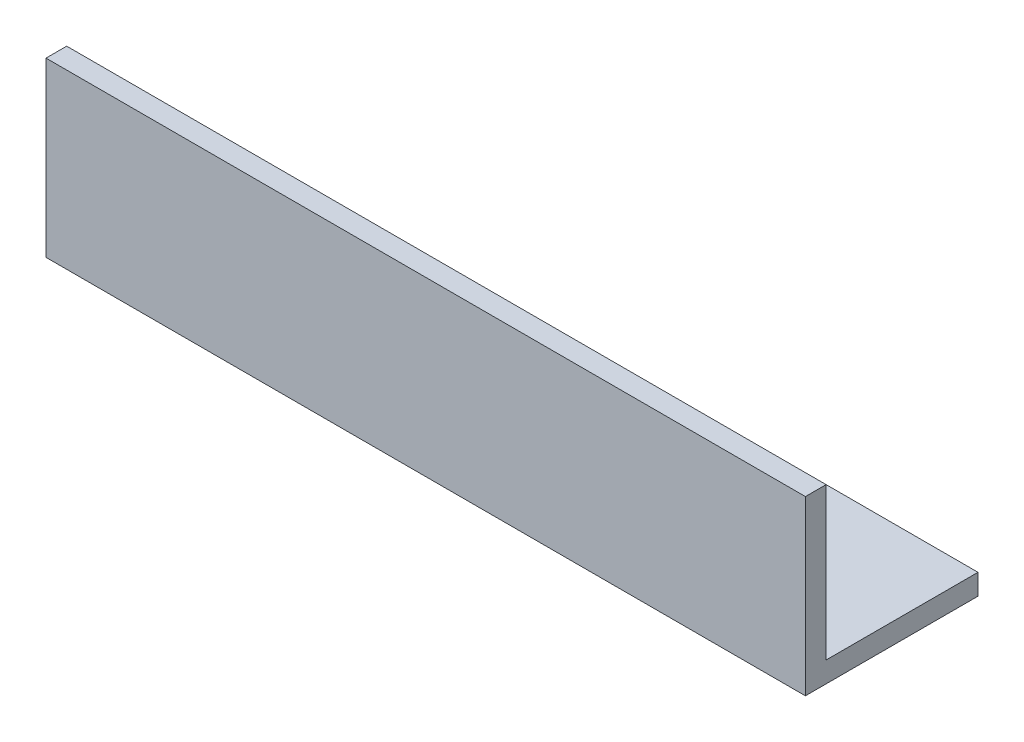
from build123d import *

# Parameters (mm, degrees)
EXTRUDE_1_DEPTH = 110


with BuildPart() as part:
    # Эскиз1 → Бобышка-Вытянуть1 (new body)
    with BuildSketch(Plane(origin=(0, 0, 0), x_dir=(0, 0, -1), z_dir=(1, 0, 0))):
        Polygon((0, 25), (0, 0), (25, 0), (25, 3), (3, 3), (3, 25), align=None)
    extrude(amount=EXTRUDE_1_DEPTH)


solid = part.part
